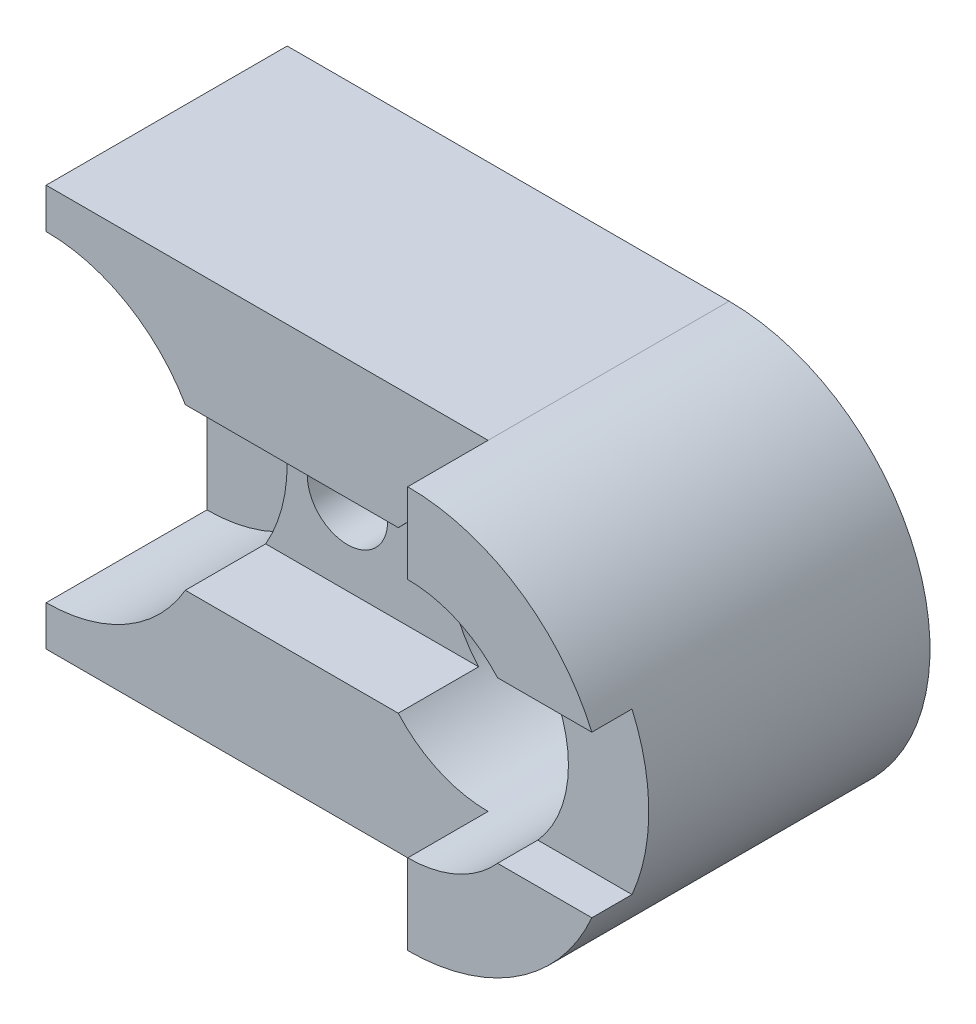
from build123d import *

# Parameters (mm, degrees)
SKETCH1_R           = 1
SKETCH1_R_2         = 1.25
BOSS_EXTRUDE1_DEPTH = 8
SKETCH2_W           = 1
SKETCH2_H           = 4
CUT_EXTRUDE1_DEPTH  = 18
CUT_EXTRUDE2_DEPTH  = 2
SKETCH4_W           = 2
SKETCH4_H           = 4
CUT_EXTRUDE3_DEPTH  = 11
SKETCH5_R           = 3
CUT_EXTRUDE4_DEPTH  = 3
SKETCH6_R           = 4
CUT_EXTRUDE5_DEPTH  = 4


with BuildPart() as part:
    # Sketch1 → Boss-Extrude1 (new body)
    with BuildSketch(Plane.XY):
        with BuildLine():
            Line((-5.5, -2), (-5.5, -5))
            Line((-5.5, -5), (5.5, -5))
            ThreePointArc((5.5, -5), (10.5, 0), (5.5, 5))
            Line((5.5, 5), (-5.5, 5))
            Line((-5.5, 5), (-5.5, 2))
            ThreePointArc((-5.5, 2), (-4.085786438, 1.414213562), (-3.5, 0))
            ThreePointArc((-3.5, 0), (-4.085786438, -1.414213562), (-5.5, -2))
        make_face()
        Circle(SKETCH1_R, mode=Mode.SUBTRACT)
        with Locations((5.5, 0)):
            Circle(SKETCH1_R_2, mode=Mode.SUBTRACT)
    extrude(amount=BOSS_EXTRUDE1_DEPTH)

    # Sketch2 → Cut-Extrude1 (cut)
    with BuildSketch(Plane.ZY.offset(5.5)):
        with Locations((7.5, 0)):
            Rectangle(SKETCH2_W, SKETCH2_H)
    extrude(amount=-CUT_EXTRUDE1_DEPTH, mode=Mode.SUBTRACT)

    # Sketch3 → Cut-Extrude2 (cut)
    with BuildSketch(Plane.XY.offset(8)):
        with BuildLine():
            Line((5.5, 3), (5.5, 5))
            Line((5.5, 5), (5.5, 6.324669678))
            Line((5.5, 6.324669678), (-9.434593506, 6.108583723))
            Line((-9.434593506, 6.108583723), (-8.586871683, -6.45764565))
            Line((-8.586871683, -6.45764565), (-0.126275451, -6.673731605))
            Line((-0.126275451, -6.673731605), (5.5, -5))
            Line((5.5, -5), (-5.5, -5))
            Line((-5.5, -5), (-5.5, -2))
            Line((-5.5, -2), (7.736067977, -2))
            ThreePointArc((7.736067977, -2), (8.238612788, 1.224744871), (5.5, 3))
        make_face()
        with BuildLine():
            ThreePointArc((5.5, -3), (6.724744871, -2.738612788), (7.736067977, -2))
            Line((7.736067977, -2), (-5.5, -2))
            Line((-5.5, -2), (-5.5, -5))
            Line((-5.5, -5), (5.5, -5))
            Line((5.5, -5), (5.5, -3))
        make_face()
    extrude(amount=-CUT_EXTRUDE2_DEPTH, mode=Mode.SUBTRACT)

    # Sketch4 → Cut-Extrude3 (cut)
    with BuildSketch(Plane.ZY.offset(5.5)):
        with Locations((5, 0)):
            Rectangle(SKETCH4_W, SKETCH4_H)
    extrude(amount=-CUT_EXTRUDE3_DEPTH, mode=Mode.SUBTRACT)

    # Sketch5 → Cut-Extrude4 (cut)
    with BuildSketch(Plane.XY.offset(6)):
        with Locations((5.5, 0)):
            Circle(SKETCH5_R)
    extrude(amount=-CUT_EXTRUDE4_DEPTH, mode=Mode.SUBTRACT)

    # Sketch6 → Cut-Extrude5 (cut)
    with BuildSketch(Plane.XY.offset(6)):
        with Locations((-5.5, 0)):
            Circle(SKETCH6_R)
    extrude(amount=-CUT_EXTRUDE5_DEPTH, mode=Mode.SUBTRACT)


solid = part.part
